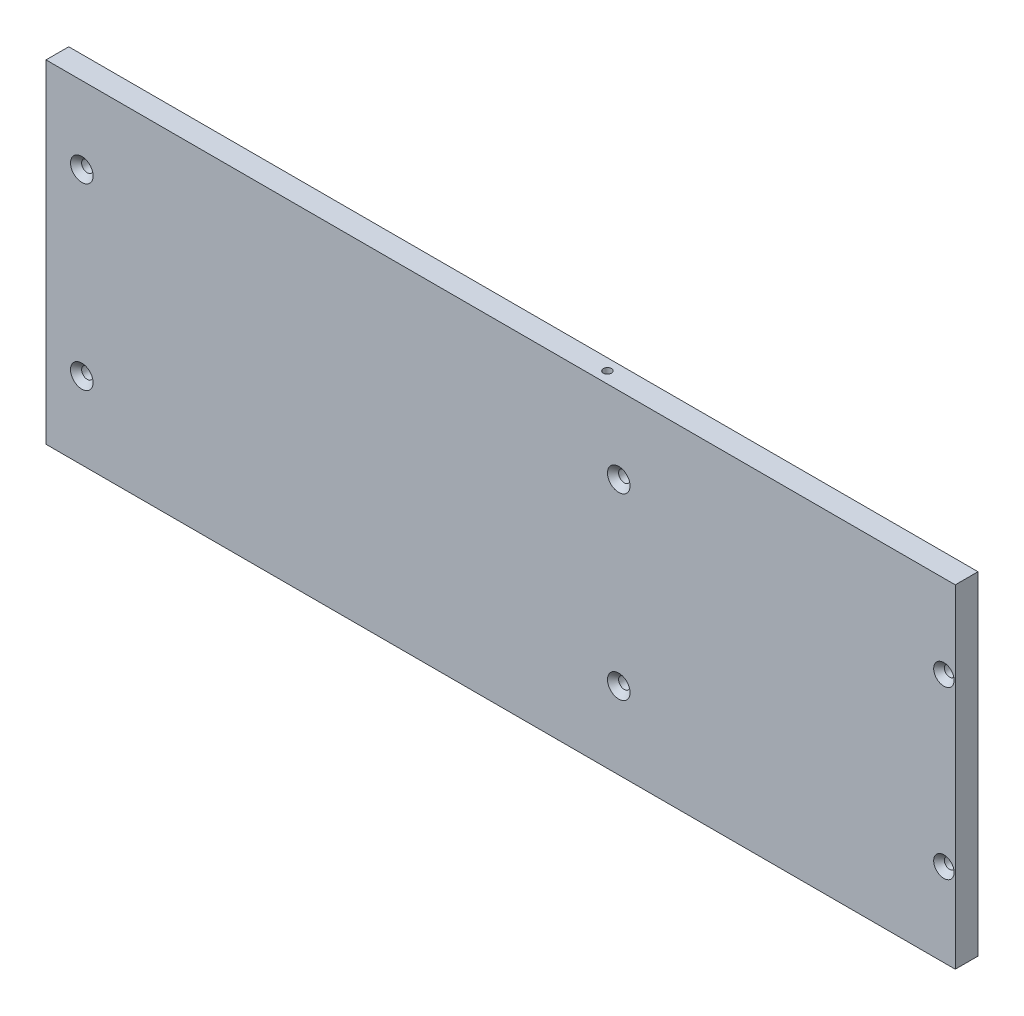
from build123d import *

# Parameters (mm, degrees)
SKETCH1_W                                       = 254
SKETCH1_H                                       = 93
BOSS_EXTRUDE1_DEPTH                             = 6.35
CSK_FOR_4_FLAT_HEAD_MACHINE_SCREW1_D            = 2.9464
CSK_FOR_4_FLAT_HEAD_MACHINE_SCREW1_CSINK_D      = 5.715
CSK_FOR_4_FLAT_HEAD_MACHINE_SCREW1_CSINK_ANGLE  = 82
CSK_FOR_M3_FLAT_HEAD_MACHINE_SCREW1_D           = 3.2
CSK_FOR_M3_FLAT_HEAD_MACHINE_SCREW1_CSINK_D     = 6.3
CSK_FOR_M3_FLAT_HEAD_MACHINE_SCREW1_CSINK_ANGLE = 90
F_4_40_TAPPED_HOLE1_D                           = 2.2606
F_4_40_TAPPED_HOLE1_DEPTH                       = 8.255
F_4_40_TAPPED_HOLE1_TIP                         = 0.679152758


with BuildPart() as part:
    # Sketch1 → Boss-Extrude1 (new body)
    with BuildSketch(Plane.XY):
        Rectangle(SKETCH1_W, SKETCH1_H)
    extrude(amount=BOSS_EXTRUDE1_DEPTH)

    # CSK for #4 Flat Head Machine Screw1 (through all)
    with Locations(Plane.XY.offset(6.35)):
        with Locations((123.825, 23.249999946), (123.825, -23.250000018)):
            CounterSinkHole(CSK_FOR_4_FLAT_HEAD_MACHINE_SCREW1_D / 2, CSK_FOR_4_FLAT_HEAD_MACHINE_SCREW1_CSINK_D / 2, counter_sink_angle=CSK_FOR_4_FLAT_HEAD_MACHINE_SCREW1_CSINK_ANGLE)

    # CSK for M3 Flat Head Machine Screw1 (through all)
    with Locations(Plane.XY.offset(6.35)):
        with Locations((-117, 25), (-117, -25), (33, -25), (33, 25)):
            CounterSinkHole(CSK_FOR_M3_FLAT_HEAD_MACHINE_SCREW1_D / 2, CSK_FOR_M3_FLAT_HEAD_MACHINE_SCREW1_CSINK_D / 2, counter_sink_angle=CSK_FOR_M3_FLAT_HEAD_MACHINE_SCREW1_CSINK_ANGLE)

    # #4-40 Tapped Hole1
    with Locations(Plane(origin=(0, 46.5, 0), x_dir=(1, 0, 0), z_dir=(0, 1, 0))):
        with Locations((26.65, -3.175)):
            Hole(F_4_40_TAPPED_HOLE1_D / 2, depth=F_4_40_TAPPED_HOLE1_DEPTH)
            with Locations((0, 0, -(F_4_40_TAPPED_HOLE1_DEPTH + F_4_40_TAPPED_HOLE1_TIP / 2))):  # 118° drill point
                Cone(0, F_4_40_TAPPED_HOLE1_D / 2, F_4_40_TAPPED_HOLE1_TIP, mode=Mode.SUBTRACT)


solid = part.part
